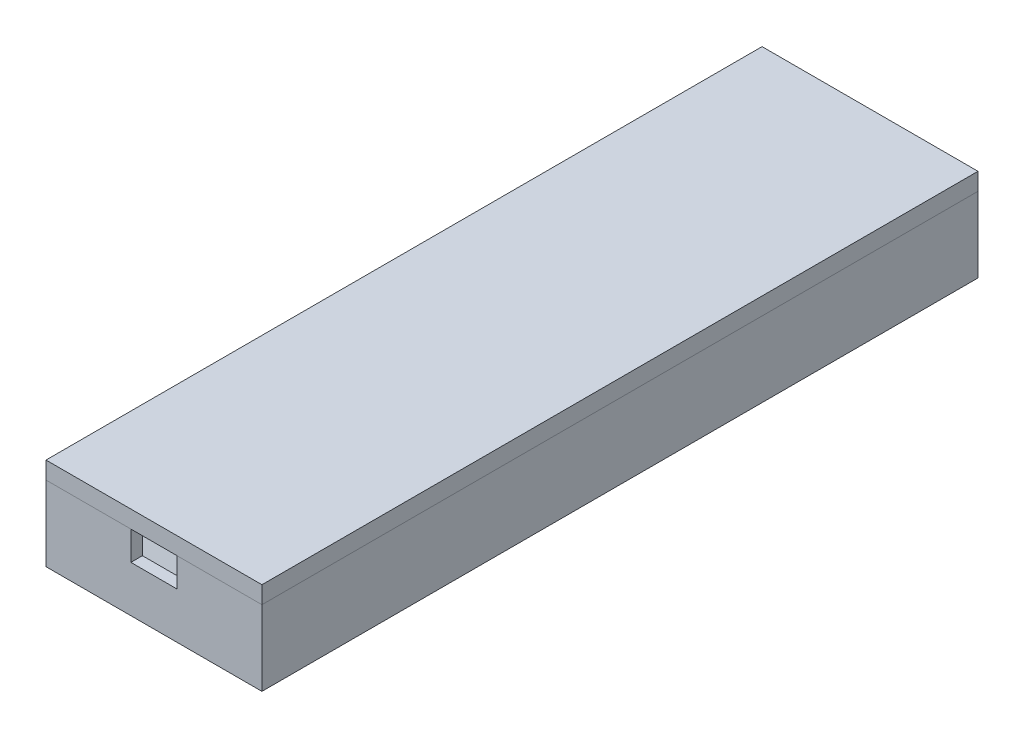
from build123d import *

# Parameters (mm, degrees)
BOSS_EXTRUDE1_DEPTH = 120
SKETCH2_W           = 37.393711542
SKETCH2_H           = 13
BOSS_EXTRUDE2_DEPTH = 2
SKETCH3_W           = 37.393711542
SKETCH3_H           = 13
BOSS_EXTRUDE3_DEPTH = 2
SKETCH5_W           = 37.393711542
SKETCH5_H           = 124
BOSS_EXTRUDE4_DEPTH = 3
SKETCH6_W           = 8
SKETCH6_H           = 5
CUT_EXTRUDE1_DEPTH  = 3


with BuildPart() as part:
    # Sketch1 → Boss-Extrude1 (new body)
    with BuildSketch(Plane.XY):
        Polygon((-18.696855771, 0), (18.696855771, 0), (18.696855771, 13), (15.696855771, 13), (0, 3), (-15.696855771, 13), (-18.696855771, 13), align=None)
    extrude(amount=BOSS_EXTRUDE1_DEPTH)

    # Sketch2 → Boss-Extrude2 (add)
    with BuildSketch(Plane(origin=(0, 0, 0), x_dir=(-1, 0, 0), z_dir=(0, 0, -1))):
        with Locations((0, 6.5)):
            Rectangle(SKETCH2_W, SKETCH2_H)
    extrude(amount=BOSS_EXTRUDE2_DEPTH)

    # Sketch3 → Boss-Extrude3 (add)
    with BuildSketch(Plane.XY.offset(120)):
        with Locations((0, 6.5)):
            Rectangle(SKETCH3_W, SKETCH3_H)
    extrude(amount=BOSS_EXTRUDE3_DEPTH)

    # Sketch6 → Cut-Extrude1 (cut)
    with BuildSketch(Plane.XY.offset(122)):
        with Locations((0, 10.5)):
            Rectangle(SKETCH6_W, SKETCH6_H)
    extrude(amount=-CUT_EXTRUDE1_DEPTH, mode=Mode.SUBTRACT)


with BuildPart() as body_2:
    # Sketch5 → Boss-Extrude4 (new body)
    with BuildSketch(Plane(origin=(0, 13, 0), x_dir=(1, 0, 0), z_dir=(0, 1, 0))):
        with Locations((0, -60)):
            Rectangle(SKETCH5_W, SKETCH5_H)
    extrude(amount=BOSS_EXTRUDE4_DEPTH)


solid = Compound([part.part, body_2.part])
